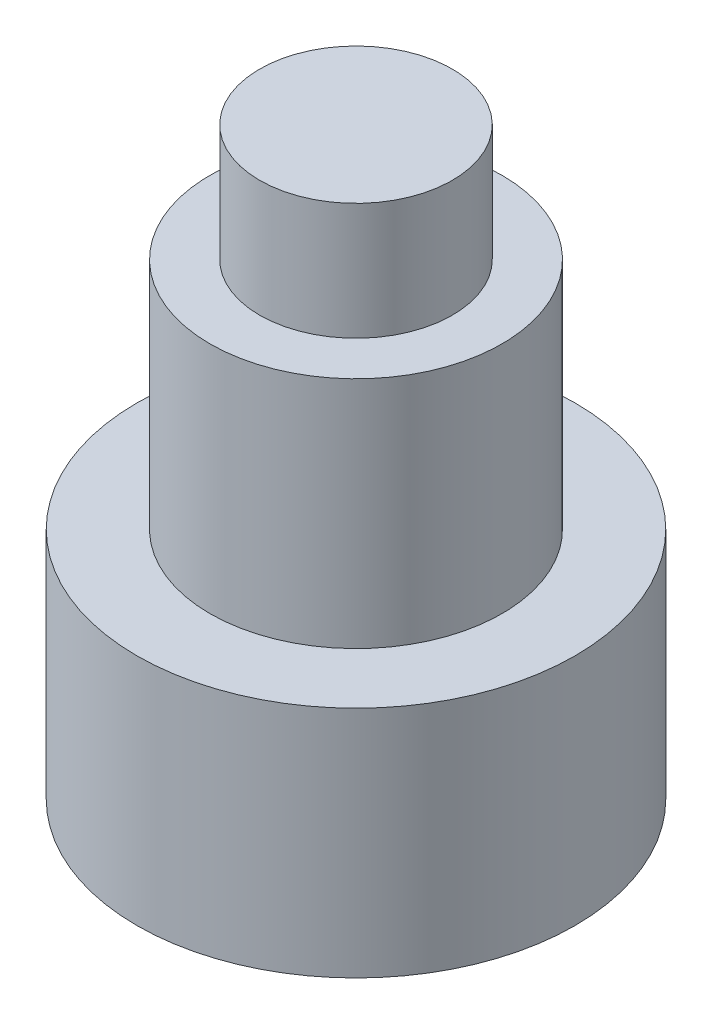
from build123d import *

# Parameters (mm, degrees)
SKETCH1_R           = 3.75
BOSS_EXTRUDE1_DEPTH = 8
SKETCH2_R           = 3.75
SKETCH2_R_2         = 2.5
CUT_EXTRUDE1_DEPTH  = 4
SKETCH3_R           = 1.65
BOSS_EXTRUDE2_DEPTH = 2


with BuildPart() as part:
    # Sketch1 → Boss-Extrude1 (new body)
    with BuildSketch(Plane(origin=(0, 0, 0), x_dir=(1, 0, 0), z_dir=(0, 1, 0))):
        Circle(SKETCH1_R)
    extrude(amount=BOSS_EXTRUDE1_DEPTH)

    # Sketch2 → Cut-Extrude1 (cut)
    with BuildSketch(Plane(origin=(0, 8, 0), x_dir=(1, 0, 0), z_dir=(0, 1, 0))):
        Circle(SKETCH2_R)
        Circle(SKETCH2_R_2, mode=Mode.SUBTRACT)
    extrude(amount=-CUT_EXTRUDE1_DEPTH, mode=Mode.SUBTRACT)

    # Sketch3 → Boss-Extrude2 (add)
    with BuildSketch(Plane(origin=(0, 8, 0), x_dir=(1, 0, 0), z_dir=(0, 1, 0))):
        Circle(SKETCH3_R)
    extrude(amount=BOSS_EXTRUDE2_DEPTH)


solid = part.part
